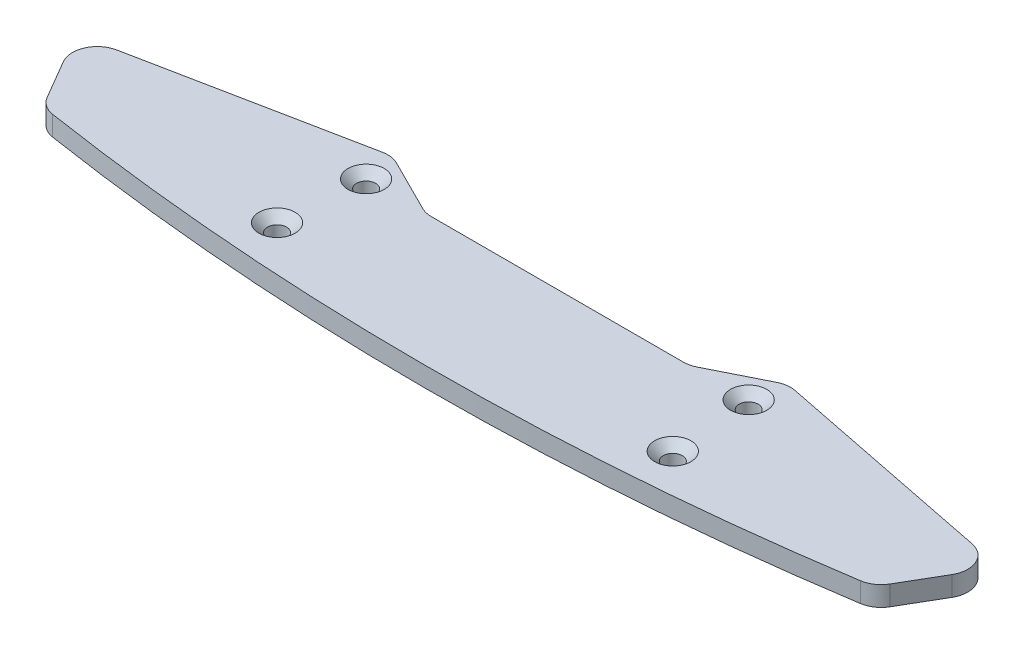
from build123d import *

# Parameters (mm, degrees)
BOSS_EXTRUDE1_DEPTH                               = 3
CSK_FOR_M2_5_FLAT_HEAD_MACHINE_SCREW1_D           = 2.9
CSK_FOR_M2_5_FLAT_HEAD_MACHINE_SCREW1_CSINK_D     = 5.5
CSK_FOR_M2_5_FLAT_HEAD_MACHINE_SCREW1_CSINK_ANGLE = 90
FILLET1_R                                         = 3.75


with BuildPart() as part:
    # Sketch1 → Boss-Extrude1 (new body)
    with BuildSketch(Plane(origin=(0, 0, 0), x_dir=(1, 0, 0), z_dir=(0, 1, 0))):
        with BuildLine():
            Line((0, 0), (0, -20))
            ThreePointArc((0, -20), (31.599050619, -18.748037795), (63, -15))
            Line((63, -15), (70, -3))
            Line((70, -3), (30, 5))
            Line((30, 5), (20, 0))
            Line((20, 0), (0, 0))
        make_face()
    boss_extrude1 = extrude(amount=BOSS_EXTRUDE1_DEPTH)

    # CSK for M2.5 Flat Head Machine Screw1 (through all)
    with Locations(Plane(origin=(0, 3, 0), x_dir=(1, 0, 0), z_dir=(0, 1, 0))):
        with Locations((29, 0), (30, -12.5)):
            csk_for_m2_5_flat_head_machine_screw1 = CounterSinkHole(CSK_FOR_M2_5_FLAT_HEAD_MACHINE_SCREW1_D / 2, CSK_FOR_M2_5_FLAT_HEAD_MACHINE_SCREW1_CSINK_D / 2, counter_sink_angle=CSK_FOR_M2_5_FLAT_HEAD_MACHINE_SCREW1_CSINK_ANGLE)

    # Mirror1: Boss-Extrude1, CSK for M2.5 Flat Head Machine Screw1 across plane
    add(boss_extrude1.mirror(Plane(origin=(0, 0, 0), x_dir=(0, 0, 1), z_dir=(1, 0, 0))))
    add(csk_for_m2_5_flat_head_machine_screw1.mirror(Plane(origin=(0, 0, 0), x_dir=(0, 0, 1), z_dir=(1, 0, 0))), mode=Mode.SUBTRACT)

    # Fillet1
    fillet1_edges = [part.edges().sort_by_distance(p)[0] for p in [
        (20, 1.5, 0),
        (30, 1.5, -5),
        (70, 1.5, 3),
        (63, 1.5, 15),
        (-20, 1.5, 0),
        (-30, 1.5, -5),
        (-70, 1.5, 3),
        (-63, 1.5, 15),
    ]]
    fillet(fillet1_edges, radius=FILLET1_R)


solid = part.part
